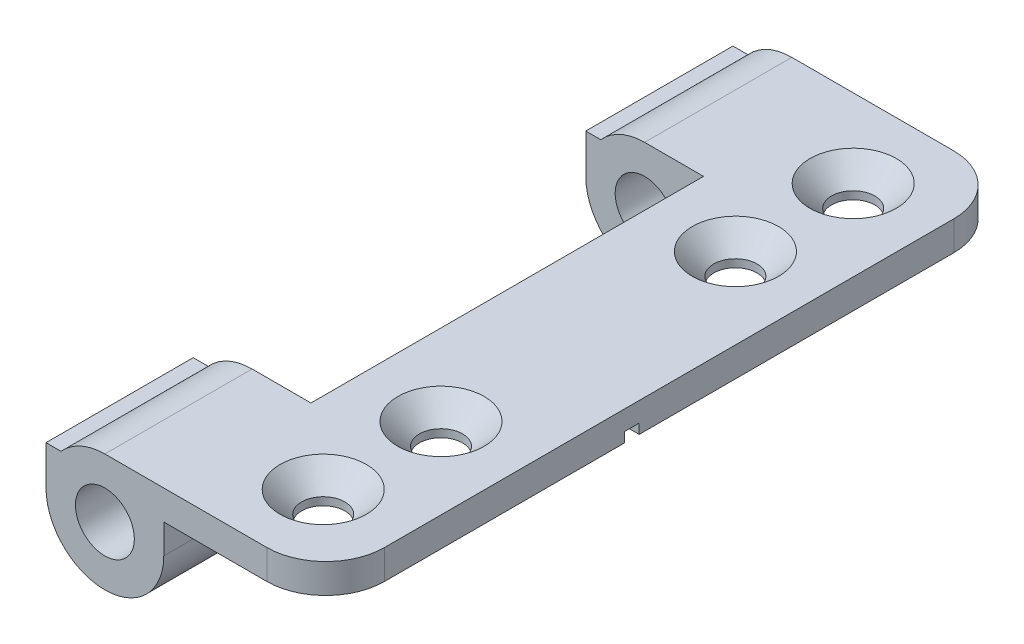
from build123d import *

# Parameters (mm, degrees)
SKETCH2_R           = 1.5
BOSS_EXTRUDE1_DEPTH = 7.5
SKETCH4_W           = 8.25
SKETCH4_H           = 1.5
BOSS_EXTRUDE3_DEPTH = 20
SKETCH5_R           = 1.5
BOSS_EXTRUDE4_DEPTH = 7.5
SKETCH6_W           = 0.75
SKETCH6_H           = 0.5
CUT_EXTRUDE1_DEPTH  = 9.25
SKETCH7_R           = 1.1
CUT_EXTRUDE2_DEPTH  = 2.5
CHAMFER1_SIZE       = 1.1
FILLET1_R           = 3


with BuildPart() as part:
    # Sketch2 → Boss-Extrude1 (new body)
    with BuildSketch(Plane.XY):
        with BuildLine():
            Line((3, 3), (11.25, 3))
            Line((11.25, 3), (11.25, 1.5))
            Line((11.25, 1.5), (3, 1.5))
            Line((3, 1.5), (3, 0))
            ThreePointArc((3, 0), (0, -3), (-3, 0))
            Line((-3, 0), (-3, 2))
            Line((-3, 2), (-2.236067977, 2))
            ThreePointArc((-2.236067977, 2), (-1.224744871, 2.738612788), (0, 3))
            Line((0, 3), (3, 3))
        make_face()
        Circle(SKETCH2_R, mode=Mode.SUBTRACT)
    extrude(amount=BOSS_EXTRUDE1_DEPTH)

    # Sketch4 → Boss-Extrude3 (add)
    with BuildSketch(Plane.XY.offset(7.5)):
        with Locations((7.125, 2.25)):
            Rectangle(SKETCH4_W, SKETCH4_H)
    extrude(amount=BOSS_EXTRUDE3_DEPTH)

    # Sketch5 → Boss-Extrude4 (add)
    with BuildSketch(Plane.XY.offset(27.5)):
        with BuildLine():
            Line((11.25, 1.5), (11.25, 3))
            Line((11.25, 3), (3, 3))
            Line((3, 3), (0, 3))
            ThreePointArc((0, 3), (-1.224744871, 2.738612788), (-2.236067977, 2))
            Line((-2.236067977, 2), (-3, 2))
            Line((-3, 2), (-3, 0))
            ThreePointArc((-3, 0), (0, -3), (3, 0))
            Line((3, 0), (3, 1.5))
            Line((3, 1.5), (11.25, 1.5))
        make_face()
        Circle(SKETCH5_R, mode=Mode.SUBTRACT)
    extrude(amount=BOSS_EXTRUDE4_DEPTH)

    # Sketch6 → Cut-Extrude1 (cut, through all)
    with BuildSketch(Plane.ZY.offset(-3)):
        with Locations((19.4, 1.75)):
            Rectangle(SKETCH6_W, SKETCH6_H)
    extrude(amount=-CUT_EXTRUDE1_DEPTH, mode=Mode.SUBTRACT)

    # Sketch7 → Cut-Extrude2 (cut, through all)
    with BuildSketch(Plane.XZ.offset(-1.5)):
        with Locations((7.125, 25)):
            Circle(SKETCH7_R)
        with Locations((7.125, 10)):
            Circle(SKETCH7_R)
        with Locations((7.125, 31)):
            Circle(SKETCH7_R)
        with Locations((7.125, 4)):
            Circle(SKETCH7_R)
    extrude(amount=-CUT_EXTRUDE2_DEPTH, mode=Mode.SUBTRACT)

    # Chamfer1
    chamfer1_edges = [part.edges().sort_by_distance(p)[0] for p in [
        (6.025, 3, 4),
        (6.025, 3, 31),
        (6.025, 3, 10),
        (6.025, 3, 25),
    ]]
    chamfer(chamfer1_edges, length=CHAMFER1_SIZE)

    # Fillet1
    fillet1_edges = [part.edges().sort_by_distance(p)[0] for p in [
        (11.25, 2.25, 35),
        (11.25, 2.25, 0),
    ]]
    fillet(fillet1_edges, radius=FILLET1_R)


solid = part.part
